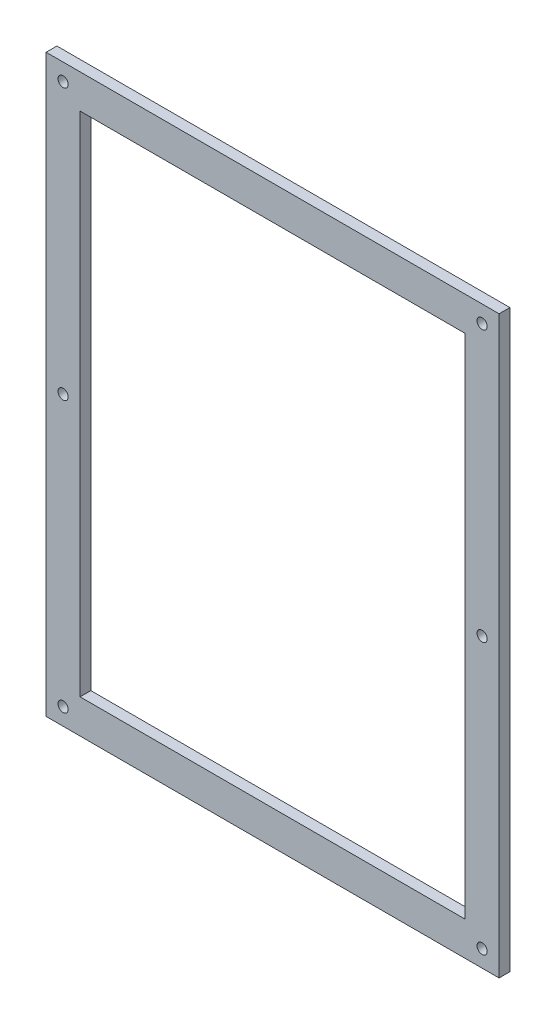
from build123d import *

# Parameters (mm, degrees)
SKETCH1_W           = 133.35
SKETCH1_H           = 169.333333333
SKETCH1_R           = 1.5
BOSS_EXTRUDE1_DEPTH = 3.175
SKETCH2_W           = 113.35
SKETCH2_H           = 149.333333333
CUT_EXTRUDE1_DEPTH  = 3.175


with BuildPart() as part:
    # Sketch1 → Boss-Extrude1 (new body)
    with BuildSketch(Plane.XY):
        with Locations((66.675, 84.666666667)):
            Rectangle(SKETCH1_W, SKETCH1_H)
        with Locations((5, 5)):
            Circle(SKETCH1_R, mode=Mode.SUBTRACT)
        with Locations((5, 164.333333333)):
            Circle(SKETCH1_R, mode=Mode.SUBTRACT)
        with Locations((5, 84.666666667)):
            Circle(SKETCH1_R, mode=Mode.SUBTRACT)
        with Locations((128.35, 164.333333333)):
            Circle(SKETCH1_R, mode=Mode.SUBTRACT)
        with Locations((128.35, 84.666666667)):
            Circle(SKETCH1_R, mode=Mode.SUBTRACT)
        with Locations((128.35, 5)):
            Circle(SKETCH1_R, mode=Mode.SUBTRACT)
    extrude(amount=BOSS_EXTRUDE1_DEPTH)

    # Sketch2 → Cut-Extrude1 (cut)
    with BuildSketch(Plane.XY.offset(3.175)):
        with Locations((66.675, 84.666666667)):
            Rectangle(SKETCH2_W, SKETCH2_H)
    extrude(amount=-CUT_EXTRUDE1_DEPTH, mode=Mode.SUBTRACT)


solid = part.part
